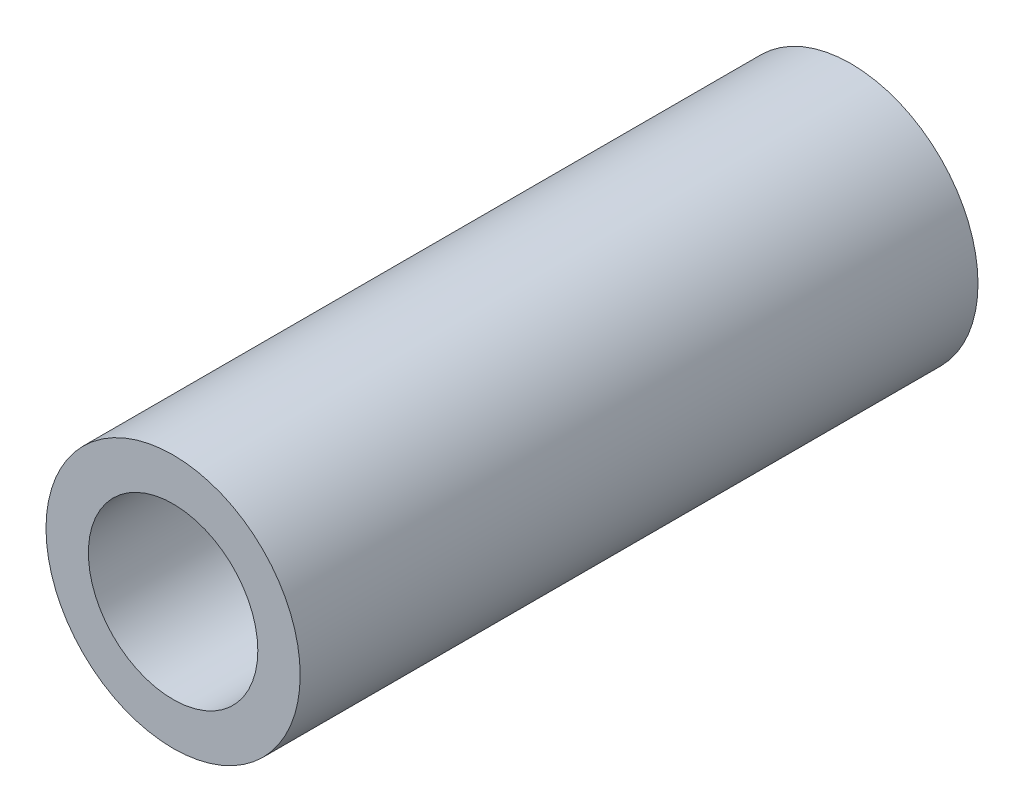
from build123d import *

# Parameters (mm, degrees)
SKETCH1_R           = 4.7625
BOSS_EXTRUDE1_DEPTH = 12.7
SKETCH2_R           = 3.175
CUT_EXTRUDE1_DEPTH  = 26.4


with BuildPart() as part:
    # Sketch1 → Boss-Extrude1 (new body, symmetric)
    with BuildSketch(Plane.XY):
        Circle(SKETCH1_R)
    extrude(amount=BOSS_EXTRUDE1_DEPTH, both=True)

    # Sketch2 → Cut-Extrude1 (cut, through all)
    with BuildSketch(Plane.XY.offset(12.7)):
        Circle(SKETCH2_R)
    extrude(amount=-CUT_EXTRUDE1_DEPTH, mode=Mode.SUBTRACT)


solid = part.part
